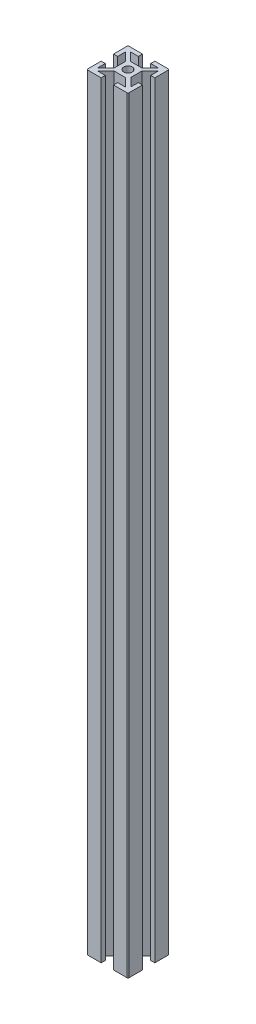
from build123d import *

# Parameters (mm, degrees)
SKETCH1_R           = 2.1
BOSS_EXTRUDE1_DEPTH = 371.25


with BuildPart() as part:
    # Sketch1 → Boss-Extrude1 (new body)
    with BuildSketch(Plane(origin=(0, 420, 0), x_dir=(1, 0, 0), z_dir=(0, 1, 0))):
        with BuildLine():
            Line((4, 2.746364236), (8, 6.746364236))
            Line((8, 6.746364236), (8, 3))
            Line((8, 3), (10, 3))
            Line((10, 3), (10, 9.5))
            ThreePointArc((10, 9.5), (9.853553391, 9.853553391), (9.5, 10))
            Line((9.5, 10), (3, 10))
            Line((3, 10), (3, 8))
            Line((3, 8), (6.863334179, 8))
            Line((6.863334179, 8), (2.863334179, 4))
            Line((2.863334179, 4), (-2.75, 4))
            Line((-2.75, 4), (-6.75, 8))
            Line((-6.75, 8), (-3, 8))
            Line((-3, 8), (-3, 10))
            Line((-3, 10), (-9.5, 10))
            ThreePointArc((-9.5, 10), (-9.853553391, 9.853553391), (-10, 9.5))
            Line((-10, 9.5), (-10, 3))
            Line((-10, 3), (-8, 3))
            Line((-8, 3), (-8, 6.75))
            Line((-8, 6.75), (-4, 2.75))
            Line((-4, 2.75), (-4, -2.75))
            Line((-4, -2.75), (-8, -6.75))
            Line((-8, -6.75), (-8, -3))
            Line((-8, -3), (-10, -3))
            Line((-10, -3), (-10, -9.5))
            ThreePointArc((-10, -9.5), (-9.853553391, -9.853553391), (-9.5, -10))
            Line((-9.5, -10), (-3, -10))
            Line((-3, -10), (-3, -8))
            Line((-3, -8), (-6.75, -8))
            Line((-6.75, -8), (-2.75, -4))
            Line((-2.75, -4), (2.868469119, -4))
            Line((2.868469119, -4), (6.868469119, -8))
            Line((6.868469119, -8), (3, -8))
            Line((3, -8), (3, -10))
            Line((3, -10), (9.5, -10))
            ThreePointArc((9.5, -10), (9.853553391, -9.853553391), (10, -9.5))
            Line((10, -9.5), (10, -3))
            Line((10, -3), (8, -3))
            Line((8, -3), (8, -6.665189266))
            Line((8, -6.665189266), (4, -2.665189266))
            Line((4, -2.665189266), (4, 2.746364236))
        make_face()
        Circle(SKETCH1_R, mode=Mode.SUBTRACT)
    extrude(amount=-BOSS_EXTRUDE1_DEPTH)


solid = part.part
